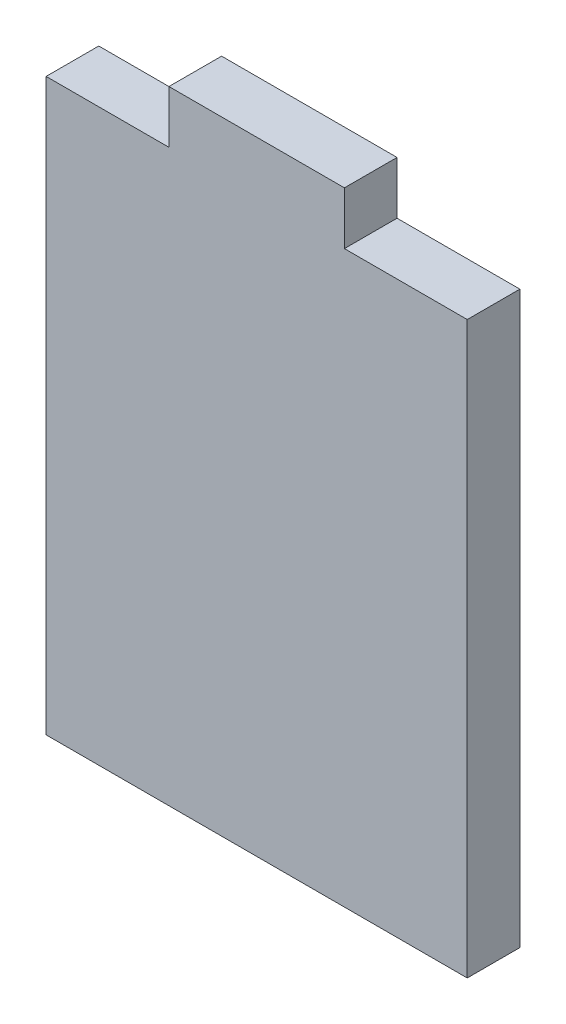
from build123d import *

# Parameters (mm, degrees)
ESQUISSE1_W        = 48
ESQUISSE1_H        = 65
BOSS_EXTRU_1_DEPTH = 6
ESQUISSE3_W        = 20
ESQUISSE3_H        = 6
BOSS_EXTRU_2_DEPTH = 6


with BuildPart() as part:
    # Esquisse1 → Boss.-Extru.1 (new body)
    with BuildSketch(Plane.XY):
        with Locations((-29.427833333, 2.816666667)):
            Rectangle(ESQUISSE1_W, ESQUISSE1_H)
    extrude(amount=BOSS_EXTRU_1_DEPTH)

    # Esquisse3 → Boss.-Extru.2 (add)
    with BuildSketch(Plane.XY.offset(6)):
        with Locations((-29.427833333, 38.316666667)):
            Rectangle(ESQUISSE3_W, ESQUISSE3_H)
    extrude(amount=-BOSS_EXTRU_2_DEPTH)


solid = part.part
